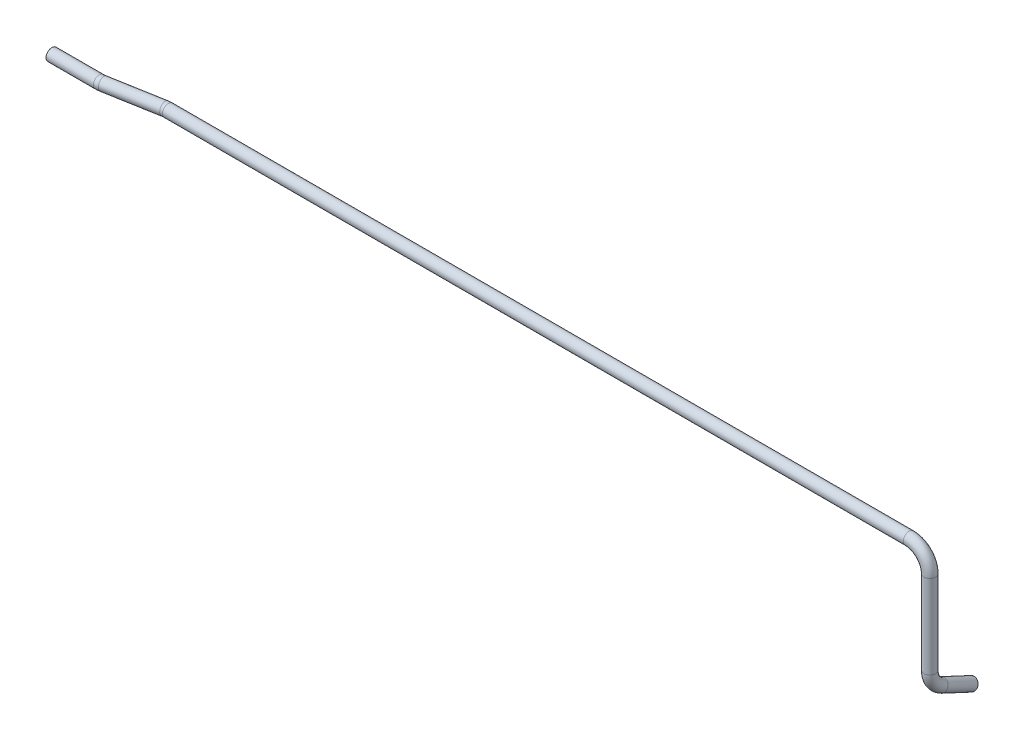
from build123d import *

# Parameters (mm, degrees)
SKETCH1_R   = 6
SKETCH1_R_2 = 4.5


with BuildPart() as part:
    # Sweep1: sweep along a curve in space
    with BuildLine() as sweep1_path:
        Line((0, 0, 0), (48.162738066, 0, 0))
        ThreePointArc((48.162738066, 0, 0), (49.993008664, 0, -0.07991134), (51.809349797, 0, -0.319037187))
        Line((51.809349797, 0, -0.319037187), (104.903468399, 0, -9.680962813))
        ThreePointArc((108.55008013, 0, -10), (106.719809533, 0, -9.92008866), (104.903468399, 0, -9.680962813))
        Line((108.55008013, 0, -10), (862.443405092, 0, -10))
        ThreePointArc((862.443405092, 0, -10), (877.292647497, -6.150757595, -10), (883.443405092, -21, -10))
        Line((883.443405092, -21, -10), (883.443405092, -106.121524523, -10))
        ThreePointArc((883.443405092, -106.121524523, -10), (883.443405092, -117.404816298, -13.288779638), (883.443405092, -125.153988051, -22.125016503))
        Line((883.443405092, -125.153988051, -22.125016503), (883.443405092, -139.363058302, -52.596465991))
    # Sketch1 → Sweep1 (sweep)
    with BuildSketch(Plane(origin=(0, 0, 0), x_dir=(0, 0, -1), z_dir=(1, 0, 0))):
        Circle(SKETCH1_R)
        Circle(SKETCH1_R_2, mode=Mode.SUBTRACT)
    sweep(path=sweep1_path.line)


solid = part.part
